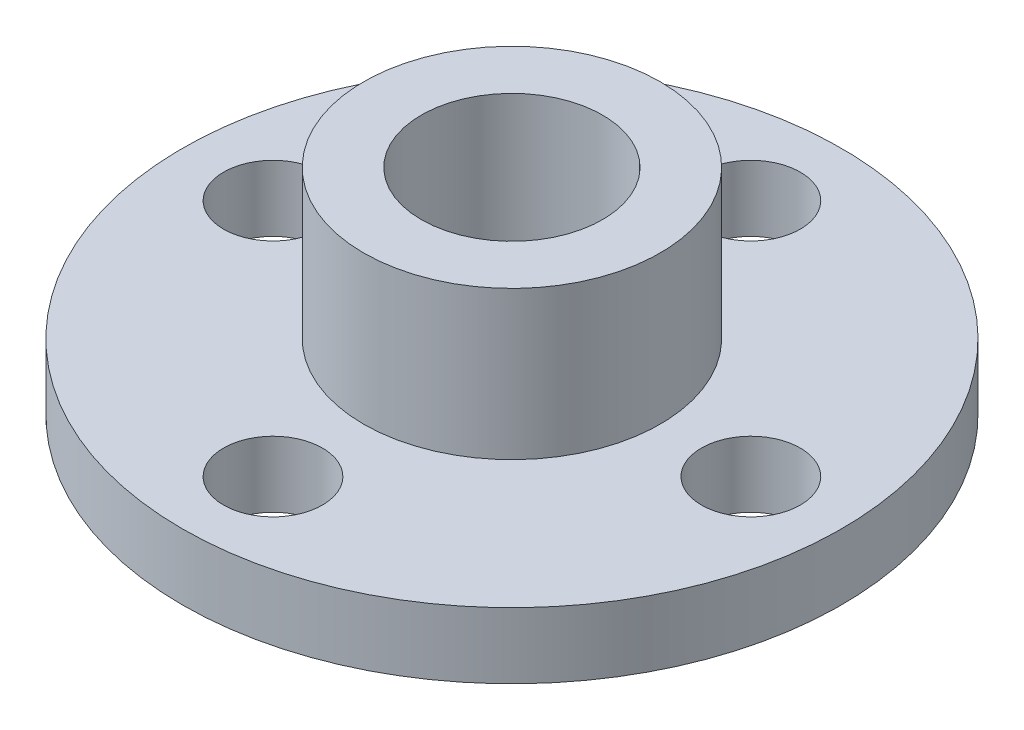
from build123d import *

# Parameters (mm, degrees)
SKETCH1_R           = 10
SKETCH1_R_2         = 1.5
SKETCH1_R_3         = 2
BOSS_EXTRUDE1_DEPTH = 2
SKETCH2_R           = 4.5
SKETCH2_R_2         = 2.75
BOSS_EXTRUDE2_DEPTH = 4.5


with BuildPart() as part:
    # Sketch1 → Boss-Extrude1 (new body)
    with BuildSketch(Plane(origin=(0, 0, 0), x_dir=(1, 0, 0), z_dir=(0, 1, 0))):
        Circle(SKETCH1_R)
        with Locations((-7.25, 0)):
            Circle(SKETCH1_R_2, mode=Mode.SUBTRACT)
        with Locations((0, 7.25)):
            Circle(SKETCH1_R_2, mode=Mode.SUBTRACT)
        with Locations((7.25, 0)):
            Circle(SKETCH1_R_2, mode=Mode.SUBTRACT)
        with Locations((0, -7.25)):
            Circle(SKETCH1_R_2, mode=Mode.SUBTRACT)
        Circle(SKETCH1_R_3, mode=Mode.SUBTRACT)
    extrude(amount=BOSS_EXTRUDE1_DEPTH)

    # Sketch2 → Boss-Extrude2 (add)
    with BuildSketch(Plane(origin=(0, 2, 0), x_dir=(1, 0, 0), z_dir=(0, 1, 0))):
        Circle(SKETCH2_R)
        Circle(SKETCH2_R_2, mode=Mode.SUBTRACT)
    extrude(amount=BOSS_EXTRUDE2_DEPTH)


solid = part.part
